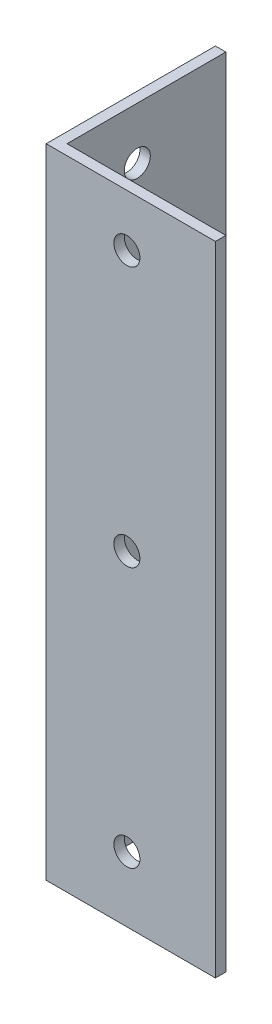
from build123d import *

# Parameters (mm, degrees)
EXTRUDE_1_DEPTH     = 245
SKETCH_2_R          = 5
CUT_EXTRUDE_1_DEPTH = 10
SKETCH_3_R          = 5
CUT_EXTRUDE_2_DEPTH = 10


with BuildPart() as part:
    # Эскиз1 → Вытянуть-Тонкостенный1 (new body)
    with BuildSketch(Plane(origin=(0, 0, 0), x_dir=(1, 0, 0), z_dir=(0, 1, 0))):
        Polygon((0, 65), (0, 0), (65, 0), (65, 4), (4, 4), (4, 65), align=None)
    extrude(amount=EXTRUDE_1_DEPTH)

    # Эскиз2 → Вырез-Вытянуть1 (cut)
    with BuildSketch(Plane.XY):
        with Locations((31, 225)):
            Circle(SKETCH_2_R)
        with Locations((31, 125)):
            Circle(SKETCH_2_R)
        with Locations((31, 25)):
            Circle(SKETCH_2_R)
    extrude(amount=-CUT_EXTRUDE_1_DEPTH, mode=Mode.SUBTRACT)

    # Эскиз3 → Вырез-Вытянуть2 (cut)
    with BuildSketch(Plane.ZY):
        with Locations((-31, 225)):
            Circle(SKETCH_3_R)
        with Locations((-31, 125)):
            Circle(SKETCH_3_R)
        with Locations((-31, 25)):
            Circle(SKETCH_3_R)
    extrude(amount=-CUT_EXTRUDE_2_DEPTH, mode=Mode.SUBTRACT)


solid = part.part
